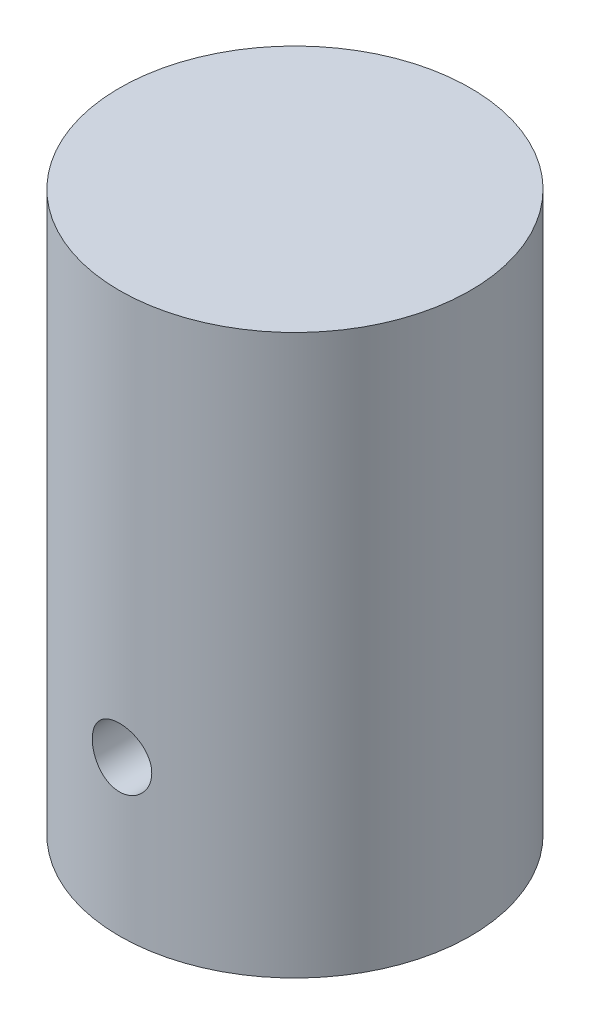
from build123d import *

# Parameters (mm, degrees)
SKETCH1_R           = 37.465
BOSS_EXTRUDE1_DEPTH = 119.38
SKETCH3_R           = 6.35
CUT_EXTRUDE1_DEPTH  = 19.05
SKETCH4_R           = 6.35
CUT_EXTRUDE2_DEPTH  = 19.05


with BuildPart() as part:
    # Sketch1 → Boss-Extrude1 (new body)
    with BuildSketch(Plane(origin=(0, 0, 0), x_dir=(1, 0, 0), z_dir=(0, 1, 0))):
        Circle(SKETCH1_R)
    extrude(amount=BOSS_EXTRUDE1_DEPTH)

    # Sketch3 → Cut-Extrude1 (cut)
    with BuildSketch(Plane.XY.offset(37.465)):
        with Locations((0, 33.02)):
            Circle(SKETCH3_R)
    extrude(amount=-CUT_EXTRUDE1_DEPTH, mode=Mode.SUBTRACT)

    # Sketch4 → Cut-Extrude2 (cut)
    with BuildSketch(Plane.XZ):
        Circle(SKETCH4_R)
    extrude(amount=-CUT_EXTRUDE2_DEPTH, mode=Mode.SUBTRACT)


solid = part.part
